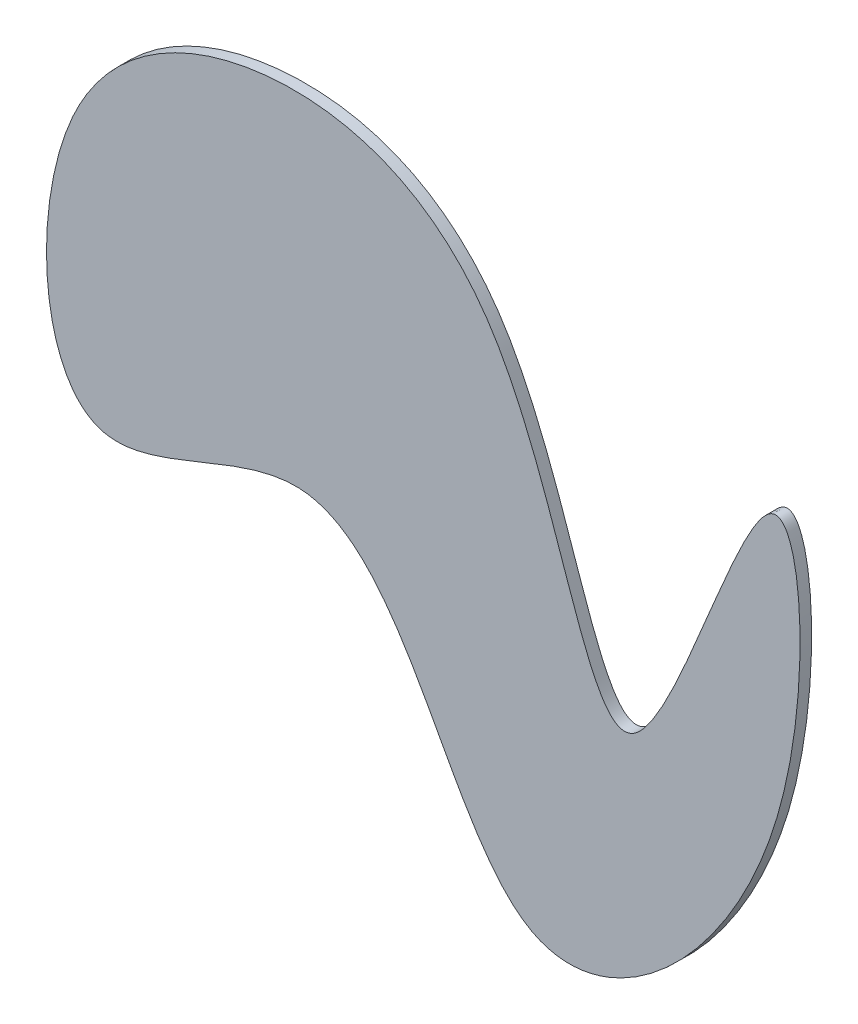
from build123d import *

# Parameters (mm, degrees)
BOSS_EXTRUDE1_DEPTH = 2.54


with BuildPart() as part:
    # Sketch1 → Boss-Extrude1 (new body)
    with BuildSketch(Plane.XY):
        with BuildLine():
            add(Edge.make_bspline(
                [(-67.67856972, 35.616402665), (-76.811463013, 15.238372242), (-74.020945849, -42.122886203), (1.051467626, 16.027966376), (22.39935106, -103.494330913), (97.147057256, -34.84277898), (89.584996774, 76.550522454), (49.883183621, -66.948643392), (34.967722877, 51.356504292), (-23.517107974, 72.228295011), (-59.067535391, 54.83002029), (-67.67856972, 35.616402665)],
                knots=[0, 0, 0, 0, 0.103468509, 0.185363414, 0.32710759, 0.460003496, 0.563109138, 0.681009482, 0.80854462, 0.902443743, 1, 1, 1, 1], degree=3))
        make_face()
    extrude(amount=BOSS_EXTRUDE1_DEPTH)


solid = part.part
